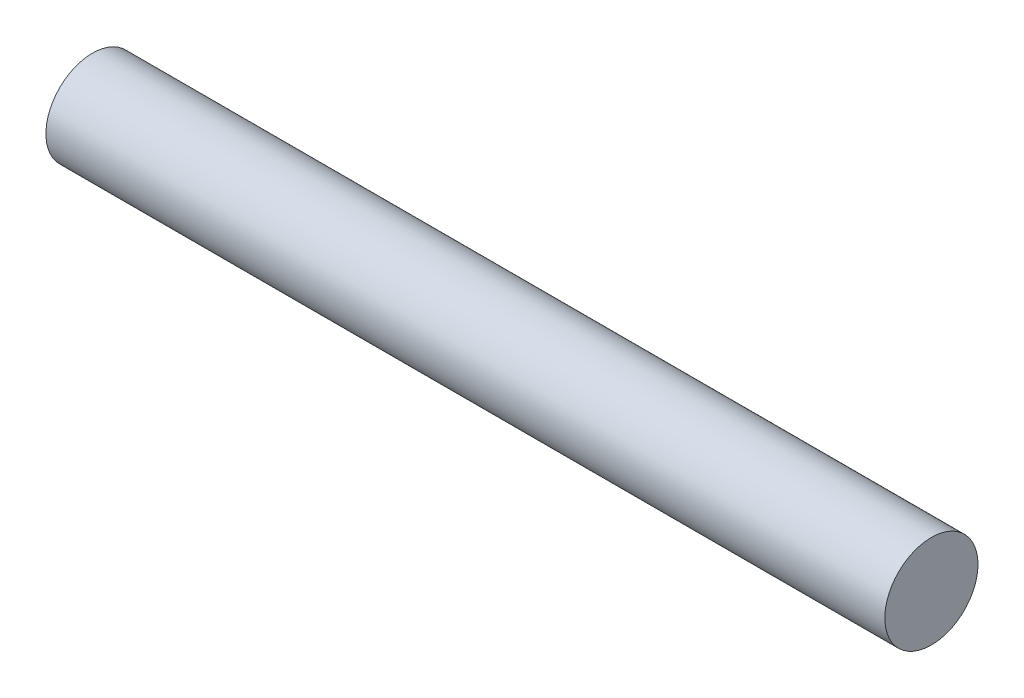
from build123d import *

# Parameters (mm, degrees)
SKETCH1_R           = 1
BOSS_EXTRUDE1_DEPTH = 9


with BuildPart() as part:
    # Sketch1 → Boss-Extrude1 (new body, symmetric)
    with BuildSketch(Plane(origin=(0, 0, 0), x_dir=(0, 0, -1), z_dir=(1, 0, 0))):
        Circle(SKETCH1_R)
    extrude(amount=BOSS_EXTRUDE1_DEPTH, both=True)


solid = part.part
